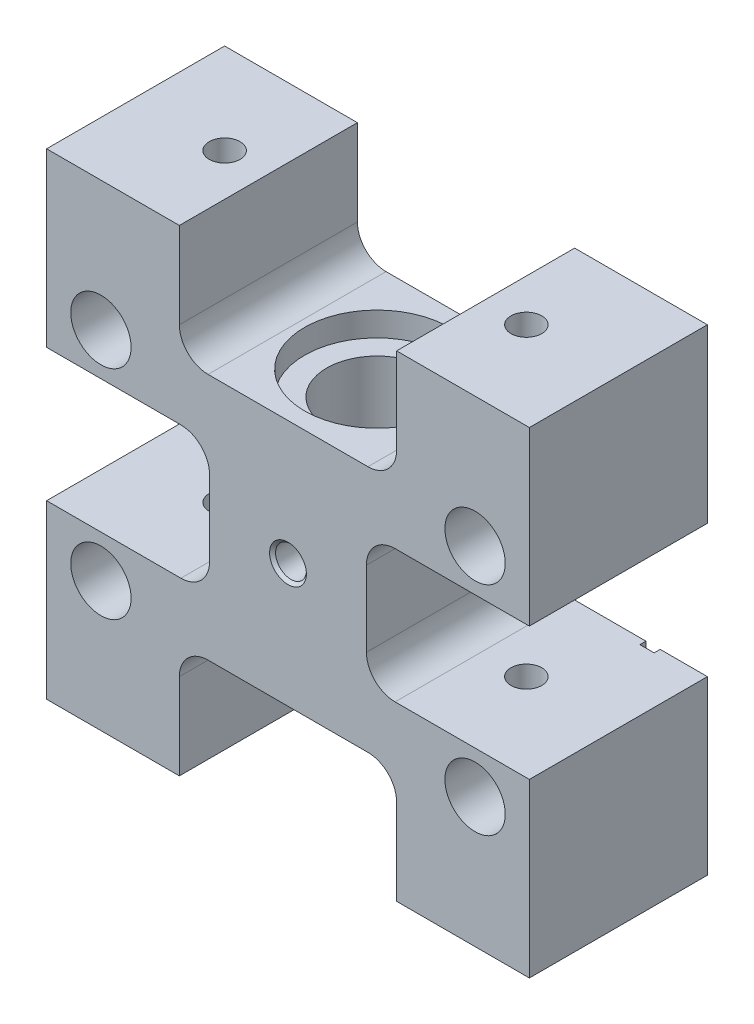
from build123d import *

# Parameters (mm, degrees)
BOSS_EXTRUDE1_DEPTH                         = 14.75
CBORE_FOR_M6_HEX_HEAD_BOLT1_D               = 6.7
CBORE_FOR_M6_HEX_HEAD_BOLT1_CBORE_D         = 10
CBORE_FOR_M6_HEX_HEAD_BOLT1_CBORE_DEPTH     = 16
TAPPED_HOLE_FOR_10_32_HELICOIL1_D           = 5.1054
TAPPED_HOLE_FOR_10_32_HELICOIL1_DEPTH       = 11.9888
TAPPED_HOLE_FOR_10_32_HELICOIL1_CSINK_D     = 6.096
TAPPED_HOLE_FOR_10_32_HELICOIL1_CSINK_ANGLE = 90
TAPPED_HOLE_FOR_10_32_HELICOIL1_TIP         = 1.533816902
F_3_4_10_TAPPED_HOLE1_D                     = 16.66748
SKETCH11_R                                  = 12
CUT_EXTRUDE1_DEPTH                          = 4
SKETCH12_R                                  = 12
CUT_EXTRUDE2_DEPTH                          = 4
F_1_4_20_TAPPED_HOLE1_D                     = 5.1054
F_1_4_20_TAPPED_HOLE1_DEPTH                 = 28.5
F_1_4_20_TAPPED_HOLE2_D                     = 5.1054
F_1_4_20_TAPPED_HOLE2_DEPTH                 = 28.5
SKETCH20_W                                  = 2.36
SKETCH20_H                                  = 33.600070702
SKETCH20_H_2                                = 33.600816511
CUT_EXTRUDE3_DEPTH                          = 1


with BuildPart() as part:
    # Sketch1 → Boss-Extrude1 (new body, symmetric)
    with BuildSketch(Plane.XY):
        with BuildLine():
            Line((18, 39.5), (40, 39.5))
            Line((40, 39.5), (40, 11))
            Line((40, 11), (17.75, 11))
            ThreePointArc((17.75, 11), (14.391242789, 9.608757211), (13, 6.25))
            Line((13, 6.25), (13, -6.25))
            ThreePointArc((13, -6.25), (14.391242789, -9.608757211), (17.75, -11))
            Line((17.75, -11), (40, -11))
            Line((40, -11), (40, -39.5))
            Line((40, -39.5), (18, -39.5))
            Line((18, -39.5), (18, -25.25))
            ThreePointArc((18, -25.25), (16.608757211, -21.891242789), (13.25, -20.5))
            Line((13.25, -20.5), (-13.25, -20.5))
            ThreePointArc((-13.25, -20.5), (-16.608757211, -21.891242789), (-18, -25.25))
            Line((-18, -25.25), (-18, -39.5))
            Line((-18, -39.5), (-40, -39.5))
            Line((-40, -39.5), (-40, -11))
            Line((-40, -11), (-17.75, -11))
            ThreePointArc((-17.75, -11), (-14.391242789, -9.608757211), (-13, -6.25))
            Line((-13, -6.25), (-13, 6.25))
            ThreePointArc((-13, 6.25), (-14.391242789, 9.608757211), (-17.75, 11))
            Line((-17.75, 11), (-40, 11))
            Line((-40, 11), (-40, 39.5))
            Line((-40, 39.5), (-18, 39.5))
            Line((-18, 39.5), (-18, 25.25))
            ThreePointArc((-18, 25.25), (-16.608757211, 21.891242789), (-13.25, 20.5))
            Line((-13.25, 20.5), (13.25, 20.5))
            ThreePointArc((13.25, 20.5), (16.608757211, 21.891242789), (18, 25.25))
            Line((18, 25.25), (18, 39.5))
        make_face()
    extrude(amount=BOSS_EXTRUDE1_DEPTH, both=True)

    # CBORE for M6 Hex Head Bolt1 (through all)
    with Locations(Plane.XY.offset(14.75)):
        with Locations((31, 18), (-31, 18), (-31, -18), (31, -18)):
            CounterBoreHole(CBORE_FOR_M6_HEX_HEAD_BOLT1_D / 2, CBORE_FOR_M6_HEX_HEAD_BOLT1_CBORE_D / 2, CBORE_FOR_M6_HEX_HEAD_BOLT1_CBORE_DEPTH)

    # Tapped Hole for #10-32 Helicoil1
    with Locations(Plane.XY.offset(14.75)):
        with Locations((0, 0)):
            CounterSinkHole(TAPPED_HOLE_FOR_10_32_HELICOIL1_D / 2, TAPPED_HOLE_FOR_10_32_HELICOIL1_CSINK_D / 2, depth=TAPPED_HOLE_FOR_10_32_HELICOIL1_DEPTH, counter_sink_angle=TAPPED_HOLE_FOR_10_32_HELICOIL1_CSINK_ANGLE)
            with Locations((0, 0, -(TAPPED_HOLE_FOR_10_32_HELICOIL1_DEPTH + TAPPED_HOLE_FOR_10_32_HELICOIL1_TIP / 2))):  # 118° drill point
                Cone(0, TAPPED_HOLE_FOR_10_32_HELICOIL1_D / 2, TAPPED_HOLE_FOR_10_32_HELICOIL1_TIP, mode=Mode.SUBTRACT)

    # 3/4-10 Tapped Hole1 (through all)
    with Locations(Plane(origin=(0, 20.5, 0), x_dir=(-1, 0, 0), z_dir=(0, 1, 0))):
        with Locations((0, 0)):
            Hole(F_3_4_10_TAPPED_HOLE1_D / 2)

    # Sketch11 → Cut-Extrude1 (cut)
    with BuildSketch(Plane(origin=(0, 20.5, 0), x_dir=(1, 0, 0), z_dir=(0, 1, 0))):
        with Locations(Location((0, 0, 0), (0, 0, 270))):  # turned: the seam where the file's is
            Circle(SKETCH11_R)
    extrude(amount=-CUT_EXTRUDE1_DEPTH, mode=Mode.SUBTRACT)

    # Sketch12 → Cut-Extrude2 (cut)
    with BuildSketch(Plane.XZ.offset(20.5)):
        with Locations(Location((0, 0, 0), (0, 0, 90))):  # turned: the seam where the file's is
            Circle(SKETCH12_R)
    extrude(amount=-CUT_EXTRUDE2_DEPTH, mode=Mode.SUBTRACT)

    # 1/4-20 Tapped Hole1
    with Locations(Plane(origin=(0, 39.5, 0), x_dir=(-1, 0, 0), z_dir=(0, 1, 0))):
        with Locations((-25, 0.25), (25, 0.25)):
            Hole(F_1_4_20_TAPPED_HOLE1_D / 2, depth=F_1_4_20_TAPPED_HOLE1_DEPTH)

    # 1/4-20 Tapped Hole2
    with Locations(Plane.XZ.offset(39.5)):
        with Locations((25, 0.25), (-25, 0.25)):
            Hole(F_1_4_20_TAPPED_HOLE2_D / 2, depth=F_1_4_20_TAPPED_HOLE2_DEPTH)

    # Sketch20 → Cut-Extrude3 (cut)
    with BuildSketch(Plane(origin=(0, 0, -14.75), x_dir=(-1, 0, 0), z_dir=(0, 0, -1))):
        with Locations((31, -0.882383927)):
            Rectangle(SKETCH20_W, SKETCH20_H)
        with Locations((-31, -0.882756832)):
            Rectangle(SKETCH20_W, SKETCH20_H_2)
    extrude(amount=-CUT_EXTRUDE3_DEPTH, mode=Mode.SUBTRACT)


solid = part.part
